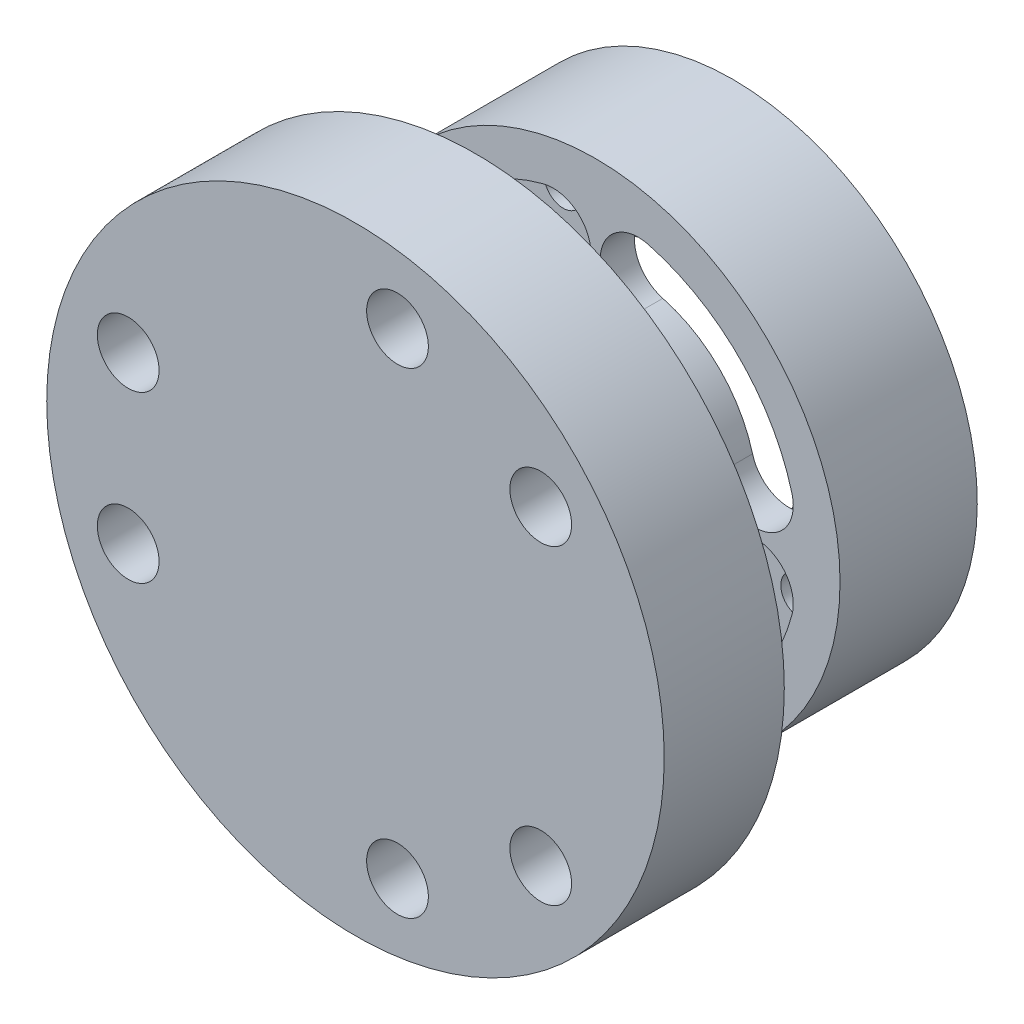
from build123d import *

# Parameters (mm, degrees)
SKETCH_1_R                   = 1.1
EXTRUDE_1_DEPTH              = 3
SKETCH_3_R                   = 14.25
SKETCH_3_R_2                 = 11.85
EXTRUDE_2_DEPTH              = 1
SKETCH_4_R                   = 14.25
EXTRUDE_3_DEPTH              = 4
SKETCH_5_R                   = 3.25
CUT_EXTRUDE_2_DEPTH          = 2.5
SKETCH_6_R                   = 3.5
EXTRUDE_4_DEPTH              = 7
SKETCH_10_R                  = 11.85
SKETCH_10_R_2                = 4.25
CUT_EXTRUDE_3_DEPTH          = 2
SKETCH_7_R                   = 18
SKETCH_7_R_2                 = 1.6
EXTRUDE_5_DEPTH              = 7
HOLE_WIZARD_M3_1_D           = 3.6
HOLE_WIZARD_M3_1_DEPTH       = 7
HOLE_WIZARD_M3_1_CSINK_D     = 6.3
HOLE_WIZARD_M3_1_CSINK_ANGLE = 90


with BuildPart() as part:
    # Sketch 1 → Extrude 1 (new body)
    with BuildSketch(Plane.XY):
        with BuildLine():
            Line((-4.25, -5.562148865), (-4.25, -13.601470509))
            ThreePointArc((-4.25, -13.601470509), (0, 14.25), (4.25, -13.601470509))
            Line((4.25, -13.601470509), (4.25, -5.562148865))
            ThreePointArc((4.25, -5.562148865), (0, 7), (-4.25, -5.562148865))
        make_face()
        with Locations((6.894291117, 6.894291117)):
            Circle(SKETCH_1_R, mode=Mode.SUBTRACT)
        with Locations((6.894291117, -6.894291117)):
            Circle(SKETCH_1_R, mode=Mode.SUBTRACT)
        with Locations((-6.894291117, -6.894291117)):
            Circle(SKETCH_1_R, mode=Mode.SUBTRACT)
        with Locations((-6.894291117, 6.894291117)):
            Circle(SKETCH_1_R, mode=Mode.SUBTRACT)
    extrude(amount=EXTRUDE_1_DEPTH)

    # Sketch 3 → Extrude 2 (add)
    with BuildSketch(Plane.XY.offset(3)):
        Circle(SKETCH_3_R)
        Circle(SKETCH_3_R_2, mode=Mode.SUBTRACT)
    extrude(amount=EXTRUDE_2_DEPTH)

    # Sketch 4 → Extrude 3 (add)
    with BuildSketch(Plane.XY.offset(4)):
        Circle(SKETCH_4_R)
        with BuildLine():
            ThreePointArc((11.446221042, 3.067005684), (8.379215357, 8.379215357), (3.067005684, 11.446221042))
            ThreePointArc((3.067005684, 11.446221042), (0.341948346, 9.872908453), (1.915260934, 7.147851115))
            ThreePointArc((1.915260934, 7.147851115), (5.232590181, 5.232590181), (7.147851115, 1.915260934))
            ThreePointArc((7.147851115, 1.915260934), (9.872908453, 0.341948346), (11.446221042, 3.067005684))
        make_face(mode=Mode.SUBTRACT)
        with BuildLine():
            ThreePointArc((3.067005684, -11.446221042), (8.379215357, -8.379215357), (11.446221042, -3.067005684))
            ThreePointArc((11.446221042, -3.067005684), (9.872908453, -0.341948346), (7.147851115, -1.915260934))
            ThreePointArc((7.147851115, -1.915260934), (5.232590181, -5.232590181), (1.915260934, -7.147851115))
            ThreePointArc((1.915260934, -7.147851115), (0.341948346, -9.872908453), (3.067005684, -11.446221042))
        make_face(mode=Mode.SUBTRACT)
        with BuildLine():
            ThreePointArc((-11.446221042, -3.067005684), (-8.379215357, -8.379215357), (-3.067005684, -11.446221042))
            ThreePointArc((-3.067005684, -11.446221042), (-0.341948346, -9.872908453), (-1.915260934, -7.147851115))
            ThreePointArc((-1.915260934, -7.147851115), (-5.232590181, -5.232590181), (-7.147851115, -1.915260934))
            ThreePointArc((-7.147851115, -1.915260934), (-9.872908453, -0.341948346), (-11.446221042, -3.067005684))
        make_face(mode=Mode.SUBTRACT)
        with BuildLine():
            ThreePointArc((-3.067005684, 11.446221042), (-8.379215357, 8.379215357), (-11.446221042, 3.067005684))
            ThreePointArc((-11.446221042, 3.067005684), (-9.872908453, 0.341948346), (-7.147851115, 1.915260934))
            ThreePointArc((-7.147851115, 1.915260934), (-5.232590181, 5.232590181), (-1.915260934, 7.147851115))
            ThreePointArc((-1.915260934, 7.147851115), (-0.341948346, 9.872908453), (-3.067005684, 11.446221042))
        make_face(mode=Mode.SUBTRACT)
        with BuildLine():
            ThreePointArc((3.393667342, 6.12233795), (0, 7), (-3.393667342, 6.12233795))
            ThreePointArc((-3.393667342, 6.12233795), (-3.929656211, 4.253122625), (-2.060440886, 3.717133755))
            ThreePointArc((-2.060440886, 3.717133755), (0, 4.25), (2.060440886, 3.717133755))
            ThreePointArc((2.060440886, 3.717133755), (3.929656211, 4.253122625), (3.393667342, 6.12233795))
        make_face(mode=Mode.SUBTRACT)
        with BuildLine():
            ThreePointArc((6.12233795, -3.393667342), (7, 0), (6.12233795, 3.393667342))
            ThreePointArc((6.12233795, 3.393667342), (4.253122625, 3.929656211), (3.717133755, 2.060440886))
            ThreePointArc((3.717133755, 2.060440886), (4.25, 0), (3.717133755, -2.060440886))
            ThreePointArc((3.717133755, -2.060440886), (4.253122625, -3.929656211), (6.12233795, -3.393667342))
        make_face(mode=Mode.SUBTRACT)
        with BuildLine():
            ThreePointArc((-3.393667342, -6.12233795), (0, -7), (3.393667342, -6.12233795))
            ThreePointArc((3.393667342, -6.12233795), (3.929656211, -4.253122625), (2.060440886, -3.717133755))
            ThreePointArc((2.060440886, -3.717133755), (0, -4.25), (-2.060440886, -3.717133755))
            ThreePointArc((-2.060440886, -3.717133755), (-3.929656211, -4.253122625), (-3.393667342, -6.12233795))
        make_face(mode=Mode.SUBTRACT)
        with BuildLine():
            ThreePointArc((-6.12233795, 3.393667342), (-7, 0), (-6.12233795, -3.393667342))
            ThreePointArc((-6.12233795, -3.393667342), (-4.253122625, -3.929656211), (-3.717133755, -2.060440886))
            ThreePointArc((-3.717133755, -2.060440886), (-4.25, 0), (-3.717133755, 2.060440886))
            ThreePointArc((-3.717133755, 2.060440886), (-4.253122625, 3.929656211), (-6.12233795, 3.393667342))
        make_face(mode=Mode.SUBTRACT)
    extrude(amount=EXTRUDE_3_DEPTH)

    # Sketch 5 → Cut-Extrude 2 (cut)
    with BuildSketch(Plane(origin=(0, 0, 4), x_dir=(-1, 0, 0), z_dir=(0, 0, -1))):
        Circle(SKETCH_5_R)
    extrude(amount=-CUT_EXTRUDE_2_DEPTH, mode=Mode.SUBTRACT)

    # Sketch 6 → Extrude 4 (add)
    with BuildSketch(Plane.XY.offset(8)):
        Circle(SKETCH_6_R)
    extrude(amount=EXTRUDE_4_DEPTH)

    # Sketch 10 → Cut-Extrude 3 (cut)
    with BuildSketch(Plane(origin=(0, 0, 4), x_dir=(-1, 0, 0), z_dir=(0, 0, -1))):
        Circle(SKETCH_10_R)
        Circle(SKETCH_10_R_2, mode=Mode.SUBTRACT)
    extrude(amount=-CUT_EXTRUDE_3_DEPTH, mode=Mode.SUBTRACT)

    # Sketch 7 → Extrude 5 (add)
    with BuildSketch(Plane.XY.offset(15)):
        Circle(SKETCH_7_R)
        with Locations((-13.249665953, 4.822484021)):
            Circle(SKETCH_7_R_2, mode=Mode.SUBTRACT)
        with Locations((-13.249665953, -4.822484021)):
            Circle(SKETCH_7_R_2, mode=Mode.SUBTRACT)
        with Locations((10.801226648, 9.063305297)):
            Circle(SKETCH_7_R_2, mode=Mode.SUBTRACT)
        with Locations((2.448439305, 13.885789317)):
            Circle(SKETCH_7_R_2, mode=Mode.SUBTRACT)
        with Locations((2.448439305, -13.885789317)):
            Circle(SKETCH_7_R_2, mode=Mode.SUBTRACT)
        with Locations((10.801226648, -9.063305297)):
            Circle(SKETCH_7_R_2, mode=Mode.SUBTRACT)
    extrude(amount=EXTRUDE_5_DEPTH)

    # Hole Wizard M3 _ _ _ _1
    with Locations(Plane(origin=(2.448439305, 13.885789317, 15), x_dir=(-1, 0, 0), z_dir=(0, 0, -1))):
        with Locations((0, 0), (15.698105258, -9.063305296), (15.698105258, -18.708273338), (0, -27.771578634), (-8.352787343, -22.949094614), (-8.352787343, -4.82248402)):
            CounterSinkHole(HOLE_WIZARD_M3_1_D / 2, HOLE_WIZARD_M3_1_CSINK_D / 2, depth=HOLE_WIZARD_M3_1_DEPTH, counter_sink_angle=HOLE_WIZARD_M3_1_CSINK_ANGLE)


solid = part.part
